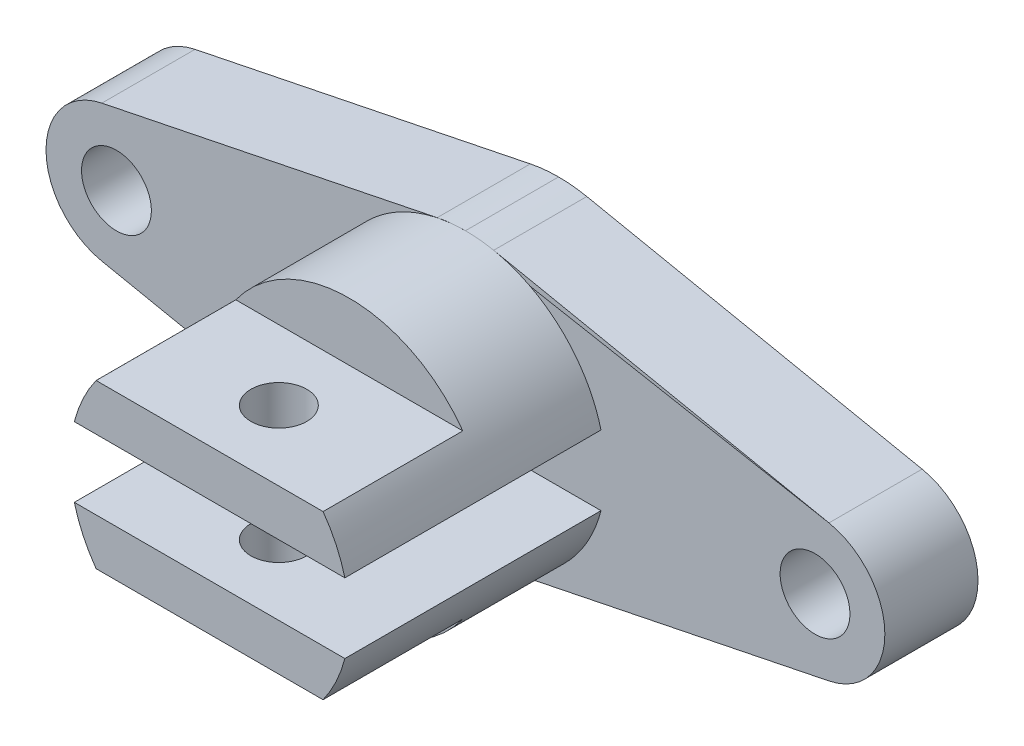
from build123d import *

# Parameters (mm, degrees)
SALIENTE_EXTRUIR1_DEPTH = 20
SALIENTE_EXTRUIR3_DEPTH = 55
CROQUIS9_W              = 48.743012572
CROQUIS9_H              = 22.844992385
CORTAR_EXTRUIR5_DEPTH   = 30
CROQUIS11_W             = 28.584477621
CROQUIS11_H             = 21.028069647
CORTAR_EXTRUIR6_DEPTH   = 30
CROQUIS12_R             = 6
CORTAR_EXTRUIR7_DEPTH   = 56
CROQUIS13_R             = 7.5
CORTAR_EXTRUIR8_DEPTH   = 56


with BuildPart() as part:
    # Croquis1 → Saliente-Extruir1 (new body)
    with BuildSketch(Plane.XY):
        with BuildLine():
            Line((153, 14.696938457), (81, 29.393876913))
            ThreePointArc((81, 29.393876913), (77.983153613, 29.851311437), (74.935446142, 29.999930547))
            ThreePointArc((74.935446142, 29.999930547), (71.887738672, 29.851311437), (68.870892285, 29.393876913))
            Line((68.870892285, 29.393876913), (-3.129107715, 14.696938457))
            ThreePointArc((-3.129107715, 14.696938457), (-15.129107715, 0), (-3.129107715, -14.696938457))
            Line((-3.129107715, -14.696938457), (68.870892285, -29.393876913))
            ThreePointArc((68.870892285, -29.393876913), (71.887738672, -29.851311437), (74.935446142, -29.999930547))
            ThreePointArc((74.935446142, -29.999930547), (77.983153613, -29.851311437), (81, -29.393876913))
            Line((81, -29.393876913), (153, -14.696938457))
            ThreePointArc((153, -14.696938457), (165, 0), (153, 14.696938457))
        make_face()
    extrude(amount=SALIENTE_EXTRUIR1_DEPTH)

    # Croquis3 → Saliente-Extruir3 (add)
    with BuildSketch(Plane.XY.offset(20)):
        with BuildLine():
            Line((45.952694142, 7.499995172), (104.047305858, 7.499995172))
            ThreePointArc((104.047305858, 7.499995172), (75, 29.999931754), (45.952694142, 7.499995172))
        make_face()
        with BuildLine():
            Line((45.952696635, -7.500004828), (104.047303365, -7.500004828))
            ThreePointArc((104.047303365, -7.500004828), (75, -29.999931754), (45.952696635, -7.500004828))
        make_face()
    extrude(amount=SALIENTE_EXTRUIR3_DEPTH)

    # Croquis9 → Cortar-Extruir5 (cut)
    with BuildSketch(Plane.XY.offset(75)):
        with Locations((75.002690531, 28.915651039)):
            Rectangle(CROQUIS9_W, CROQUIS9_H)
        with BuildLine():
            Line((50.640227559, -17.506845154), (99.365153503, -17.506845154))
            ThreePointArc((99.365153503, -17.506845154), (75.002690531, -30.000549202), (50.640227559, -17.506845154))
        make_face()
    extrude(amount=-CORTAR_EXTRUIR5_DEPTH, mode=Mode.SUBTRACT)

    # Croquis11 → Cortar-Extruir6 (cut)
    with BuildSketch(Plane.XY.offset(75)):
        with Locations((60.708867109, -28.020879978)):
            Rectangle(CROQUIS11_W, CROQUIS11_H)
    extrude(amount=-CORTAR_EXTRUIR6_DEPTH, mode=Mode.SUBTRACT)

    # Croquis12 → Cortar-Extruir7 (cut)
    with BuildSketch(Plane(origin=(0, 17.493154846, 0), x_dir=(1, 0, 0), z_dir=(0, 1, 0))):
        with Locations((74.870892285, -60)):
            Circle(CROQUIS12_R)
    extrude(amount=-CORTAR_EXTRUIR7_DEPTH, mode=Mode.SUBTRACT)

    # Croquis13 → Cortar-Extruir8 (cut)
    with BuildSketch(Plane.XY.offset(20)):
        Circle(CROQUIS13_R)
        with Locations((150.002572471, -0.006431991)):
            Circle(CROQUIS13_R)
    extrude(amount=-CORTAR_EXTRUIR8_DEPTH, mode=Mode.SUBTRACT)


solid = part.part
